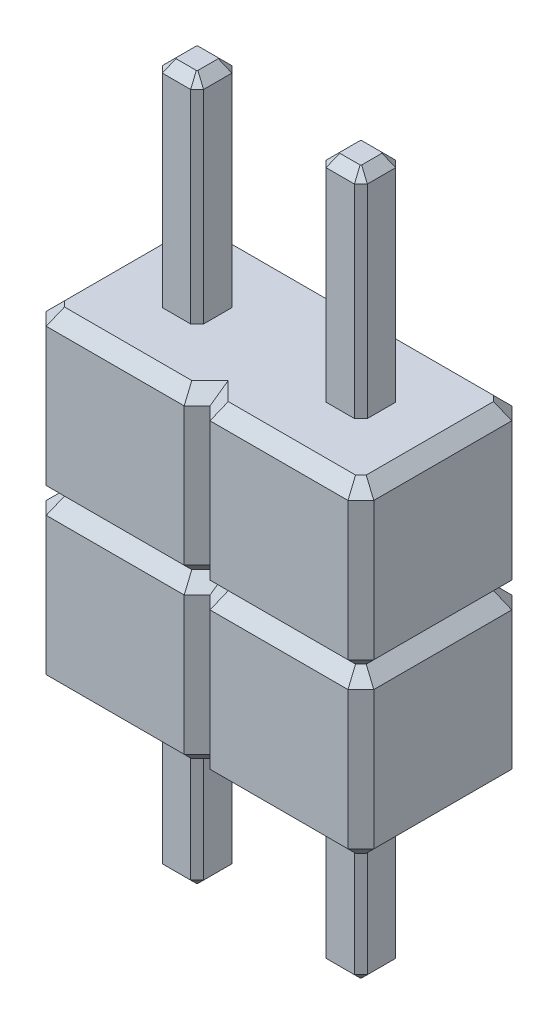
from build123d import *

# Parameters (mm, degrees)
EXTRUDE_1_DEPTH   = 2.54
EXTRUDE_1_2_DEPTH = 2.54
EXTRUDE_2_DEPTH   = 8.38
EXTRUDE_3_DEPTH   = 2.54
EXTRUDE_START     = 2.54
EXTRUDE_4_DEPTH   = 2.54
CHAMFER_1_SIZE    = 0.15
CHAMFER_2_SIZE    = 0.2
CHAMFER_3_SIZE    = 0.2


with BuildPart() as part:
    # Эскиз1 → Бобышка-Вытянуть1 (new body)
    with BuildSketch(Plane(origin=(0, 0, 0), x_dir=(1, 0, 0), z_dir=(0, 1, 0))):
        Polygon((-1.49, 0.32), (-1.59, 0.22), (-1.59, -0.22), (-1.49, -0.32), (-1.05, -0.32), (-0.95, -0.22), (-0.95, 0.22), (-1.05, 0.32), align=None)
    extrude(amount=-EXTRUDE_1_DEPTH)



with BuildPart() as body_2:
    # Эскиз1 → Extrude 1 2 (new body)
    with BuildSketch(Plane(origin=(0, 0, 0), x_dir=(1, 0, 0), z_dir=(0, 1, 0))):
        Polygon((1.05, 0.32), (0.95, 0.22), (0.95, -0.22), (1.05, -0.32), (1.49, -0.32), (1.59, -0.22), (1.59, 0.22), (1.49, 0.32), align=None)
    extrude(amount=-EXTRUDE_1_2_DEPTH)


with BuildPart() as part_1:
    add(part.part)

    add(body_2.part)  # Бобышка-Вытянуть2 merges body 2
    # Эскиз1<3> → Бобышка-Вытянуть2 (add)
    with BuildSketch(Plane(origin=(0, 0, 0), x_dir=(1, 0, 0), z_dir=(0, 1, 0))):
        Polygon((-1.49, 0.32), (-1.59, 0.22), (-1.59, -0.22), (-1.49, -0.32), (-1.05, -0.32), (-0.95, -0.22), (-0.95, 0.22), (-1.05, 0.32), align=None)
        Polygon((1.05, 0.32), (0.95, 0.22), (0.95, -0.22), (1.05, -0.32), (1.49, -0.32), (1.59, -0.22), (1.59, 0.22), (1.49, 0.32), align=None)
    extrude(amount=EXTRUDE_2_DEPTH)

    # Эскиз1<4> → Бобышка-Вытянуть3 (add)
    with BuildSketch(Plane(origin=(0, 0, 0), x_dir=(1, 0, 0), z_dir=(0, 1, 0))):
        Polygon((-0.2, 1.27), (-2.34, 1.27), (-2.54, 1.07), (-2.54, -1.07), (-2.34, -1.27), (-0.2, -1.27), (0, -1.07), (0.2, -1.27), (2.34, -1.27), (2.54, -1.07), (2.54, 1.07), (2.34, 1.27), (0.2, 1.27), (0, 1.07), align=None)
        Polygon((-1.59, -0.22), (-1.59, 0.22), (-1.49, 0.32), (-1.05, 0.32), (-0.95, 0.22), (-0.95, -0.22), (-1.05, -0.32), (-1.49, -0.32), align=None, mode=Mode.SUBTRACT)
        Polygon((0.95, 0.22), (1.05, 0.32), (1.49, 0.32), (1.59, 0.22), (1.59, -0.22), (1.49, -0.32), (1.05, -0.32), (0.95, -0.22), align=None, mode=Mode.SUBTRACT)
    extrude(amount=EXTRUDE_3_DEPTH)

    # Фаска1
    chamfer_1_edges = [part_1.edges().sort_by_distance(p)[0] for p in [
        (-1.54, -2.54, 0.27),
        (-1.27, -2.54, 0.32),
        (-1, -2.54, 0.27),
        (-0.95, -2.54, 0),
        (-1, -2.54, -0.27),
        (-1.27, -2.54, -0.32),
        (-1.54, -2.54, -0.27),
        (-1.59, -2.54, 0),
        (1, -2.54, 0.27),
        (1.27, -2.54, 0.32),
        (1.54, -2.54, 0.27),
        (1.59, -2.54, 0),
        (1.54, -2.54, -0.27),
        (1.27, -2.54, -0.32),
        (1, -2.54, -0.27),
        (0.95, -2.54, 0),
        (1, 8.38, -0.27),
        (1.27, 8.38, -0.32),
        (1.54, 8.38, -0.27),
        (1.59, 8.38, 0),
        (1.54, 8.38, 0.27),
        (1.27, 8.38, 0.32),
        (1, 8.38, 0.27),
        (0.95, 8.38, 0),
        (-1.54, 8.38, -0.27),
        (-1.27, 8.38, -0.32),
        (-1, 8.38, -0.27),
        (-0.95, 8.38, 0),
        (-1, 8.38, 0.27),
        (-1.27, 8.38, 0.32),
        (-1.54, 8.38, 0.27),
        (-1.59, 8.38, 0),
    ]]
    chamfer(chamfer_1_edges, length=CHAMFER_1_SIZE)

    # Фаска2
    chamfer_2_edges = [part_1.edges().sort_by_distance(p)[0] for p in [
        (-2.44, 2.54, -1.17),
        (-1.27, 2.54, -1.27),
        (-0.1, 2.54, -1.17),
        (0.1, 2.54, -1.17),
        (1.27, 2.54, -1.27),
        (2.44, 2.54, -1.17),
        (2.54, 2.54, 0),
        (2.44, 2.54, 1.17),
        (1.27, 2.54, 1.27),
        (0.1, 2.54, 1.17),
        (-0.1, 2.54, 1.17),
        (-1.27, 2.54, 1.27),
        (-2.44, 2.54, 1.17),
        (-2.54, 2.54, 0),
        (-2.44, 0, 1.17),
        (-1.27, 0, 1.27),
        (-0.1, 0, 1.17),
        (0.1, 0, 1.17),
        (1.27, 0, 1.27),
        (2.44, 0, 1.17),
        (2.54, 0, 0),
        (2.44, 0, -1.17),
        (1.27, 0, -1.27),
        (0.1, 0, -1.17),
        (-0.1, 0, -1.17),
        (-1.27, 0, -1.27),
        (-2.44, 0, -1.17),
        (-2.54, 0, 0),
    ]]
    chamfer(chamfer_2_edges, length=CHAMFER_2_SIZE)


with BuildPart() as body_2_2:
    # Эскиз1<5> → Бобышка-Вытянуть4 (new body)
    with BuildSketch(Plane(origin=(0, 0, 0), x_dir=(1, 0, 0), z_dir=(0, 1, 0)).offset(EXTRUDE_START)):
        Polygon((-0.2, 1.27), (-2.34, 1.27), (-2.54, 1.07), (-2.54, -1.07), (-2.34, -1.27), (-0.2, -1.27), (0, -1.07), (0.2, -1.27), (2.34, -1.27), (2.54, -1.07), (2.54, 1.07), (2.34, 1.27), (0.2, 1.27), (0, 1.07), align=None)
        Polygon((-1.59, -0.22), (-1.59, 0.22), (-1.49, 0.32), (-1.05, 0.32), (-0.95, 0.22), (-0.95, -0.22), (-1.05, -0.32), (-1.49, -0.32), align=None, mode=Mode.SUBTRACT)
        Polygon((0.95, 0.22), (1.05, 0.32), (1.49, 0.32), (1.59, 0.22), (1.59, -0.22), (1.49, -0.32), (1.05, -0.32), (0.95, -0.22), align=None, mode=Mode.SUBTRACT)
    extrude(amount=EXTRUDE_4_DEPTH)

    # Фаска3
    chamfer_3_edges = [body_2_2.edges().sort_by_distance(p)[0] for p in [
        (-2.44, 5.08, -1.17),
        (-1.27, 5.08, -1.27),
        (-0.1, 5.08, -1.17),
        (0.1, 5.08, -1.17),
        (1.27, 5.08, -1.27),
        (2.44, 5.08, -1.17),
        (2.54, 5.08, 0),
        (2.44, 5.08, 1.17),
        (1.27, 5.08, 1.27),
        (0.1, 5.08, 1.17),
        (-0.1, 5.08, 1.17),
        (-1.27, 5.08, 1.27),
        (-2.44, 5.08, 1.17),
        (-2.54, 5.08, 0),
        (-2.44, 2.54, 1.17),
        (-1.27, 2.54, 1.27),
        (-0.1, 2.54, 1.17),
        (0.1, 2.54, 1.17),
        (1.27, 2.54, 1.27),
        (2.44, 2.54, 1.17),
        (2.54, 2.54, 0),
        (2.44, 2.54, -1.17),
        (1.27, 2.54, -1.27),
        (0.1, 2.54, -1.17),
        (-0.1, 2.54, -1.17),
        (-1.27, 2.54, -1.27),
        (-2.44, 2.54, -1.17),
        (-2.54, 2.54, 0),
    ]]
    chamfer(chamfer_3_edges, length=CHAMFER_3_SIZE)


solid = Compound([part_1.part, body_2_2.part])
